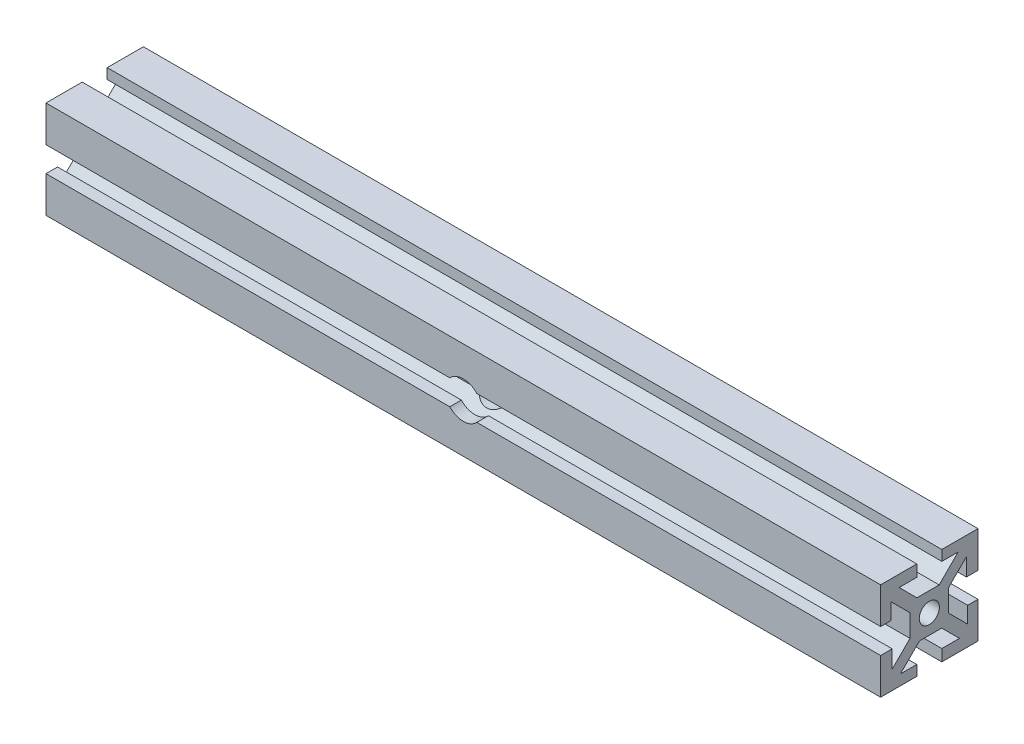
from build123d import *

# Parameters (mm, degrees)
SKETCH1_R               = 2.605
BOSS_EXTRUDE1_DEPTH     = 215.9
CIRPATTERN1_COUNT       = 4
CUT_EXTRUDE2_DEPTH      = 10
CUT_EXTRUDE2_DEPTH_BACK = 50
SKETCH2_R               = 4.765


with BuildPart() as part:
    # Sketch1 → Boss-Extrude1 (new body)
    with BuildSketch(Plane(origin=(0, 0, 0), x_dir=(0, 0, -1), z_dir=(1, 0, 0))):
        Polygon((5, -5), (5, 3.203948776), (9.596194078, 7.800142853), (9.596194078, 3.24), (12.596194078, 3.24), (12.596194078, 12.596194078), (3.24, 12.596194078), (3.24, 9.921463197), (7.474873734, 9.921463197), (2.553410537, 5), (-5, 5), (-5, -5), align=None)
        Circle(SKETCH1_R, mode=Mode.SUBTRACT)
    boss_extrude1 = extrude(amount=BOSS_EXTRUDE1_DEPTH)

    # CirPattern1: Boss-Extrude1 ×4 about axis
    cirpattern1_axis = Axis((0, 0, 0), (1, 0, 0))
    for i in range(1, CIRPATTERN1_COUNT):
        add(boss_extrude1.rotate(cirpattern1_axis, i * 360 / CIRPATTERN1_COUNT))

    # Sketch2 → Cut-Extrude2 (cut, two sides: drawn at the far end of the back side and taken through both)
    with BuildSketch(Plane.XY.offset(12.596194078).offset(-CUT_EXTRUDE2_DEPTH_BACK)):
        with Locations((107.95, 0)):
            Circle(SKETCH2_R)
    extrude(amount=CUT_EXTRUDE2_DEPTH + CUT_EXTRUDE2_DEPTH_BACK, mode=Mode.SUBTRACT)


solid = part.part
